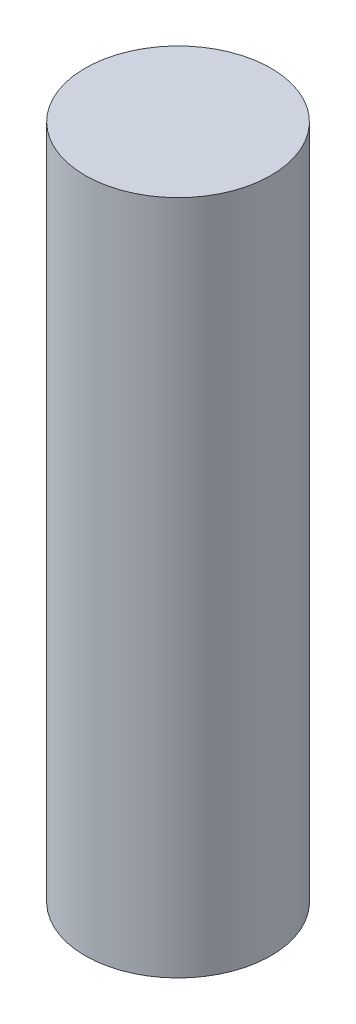
from build123d import *

# Parameters (mm, degrees)
SKETCH1_R           = 12.375
BOSS_EXTRUDE1_DEPTH = 90


with BuildPart() as part:
    # Sketch1 → Boss-Extrude1 (new body)
    with BuildSketch(Plane(origin=(0, 0, 0), x_dir=(1, 0, 0), z_dir=(0, 1, 0))):
        Circle(SKETCH1_R)
    extrude(amount=BOSS_EXTRUDE1_DEPTH)


solid = part.part
